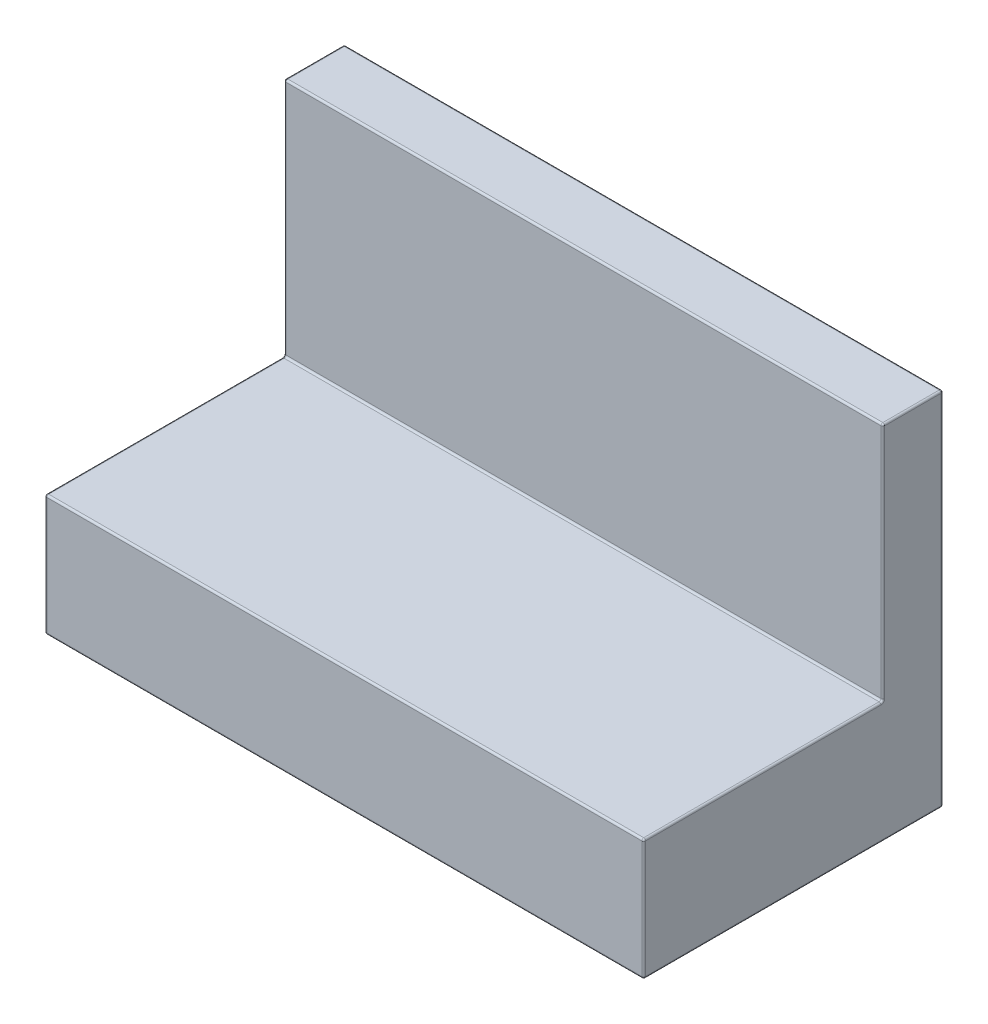
from build123d import *

# Parameters (mm, degrees)
SKETCH1_W       = 7.96
SKETCH1_H       = 7.96
EXTRUDE1_DEPTH  = 3.22
LPATTERN1_COUNT = 2
LPATTERN1_PITCH = 7.96
SHELL1_T        = -1.55
SKETCH4_W       = 12.82
SKETCH4_H       = 4.86
EXTRUDE3_DEPTH  = 0.14
SKETCH5_R       = 1.5
SKETCH5_R_2     = 0.64
EXTRUDE4_DEPTH  = 1.81
SKETCH6_W       = 15.92
SKETCH6_H       = 1.6
EXTRUDE5_DEPTH  = 6.38
FILLET1_R       = 0.05


with BuildPart() as part:
    # Sketch1 → Extrude1 (new body)
    with BuildSketch(Plane(origin=(0, 0, 0), x_dir=(1, 0, 0), z_dir=(0, 1, 0))):
        Rectangle(SKETCH1_W, SKETCH1_H)
    extrude1 = extrude(amount=EXTRUDE1_DEPTH)

    # LPattern1: Extrude1 ×2
    with Locations(*[(i * LPATTERN1_PITCH, 0, 0) for i in range(1, LPATTERN1_COUNT)]):
        add(extrude1)

    # Shell1
    shell1_openings = [part.faces().sort_by_distance(p)[0] for p in [
        (3.98, 0, 0),
    ]]
    offset(amount=SHELL1_T, openings=shell1_openings, kind=Kind.INTERSECTION)

    # Sketch4 → Extrude3 (cut)
    with BuildSketch(Plane.XZ.offset(-1.67)):
        with Locations((3.98, 0)):
            Rectangle(SKETCH4_W, SKETCH4_H)
    extrude(amount=-EXTRUDE3_DEPTH, mode=Mode.SUBTRACT)

    # Sketch5 → Extrude4 (add)
    with BuildSketch(Plane.XZ.offset(-1.81)):
        with Locations((3.98, 0)):
            Circle(SKETCH5_R)
        with Locations((3.98, 0)):
            Circle(SKETCH5_R_2, mode=Mode.SUBTRACT)
    extrude(amount=EXTRUDE4_DEPTH)

    # Sketch6 → Extrude5 (add)
    with BuildSketch(Plane(origin=(0, 3.22, 0), x_dir=(1, 0, 0), z_dir=(0, 1, 0))):
        with Locations((3.98, 3.18)):
            Rectangle(SKETCH6_W, SKETCH6_H)
    extrude(amount=EXTRUDE5_DEPTH)

    # Fillet1
    fillet1_edges = [part.edges().sort_by_distance(p)[0] for p in [
        (3.98, 3.22, 3.98),
        (11.94, 0, 0),
        (11.94, 1.61, 3.98),
        (11.94, 4.8, -3.98),
        (11.94, 3.22, 0.8),
        (3.98, 0, -2.43),
        (10.39, 0.905, -2.43),
        (-2.43, 0, 0),
        (-2.43, 0.905, -2.43),
        (3.98, 0, 2.43),
        (-2.43, 0.905, 2.43),
        (10.39, 0, 0),
        (10.39, 0.905, 2.43),
        (3.98, 1.81, 2.43),
        (10.39, 1.81, 0),
        (3.98, 1.81, -2.43),
        (-2.43, 1.81, 0),
        (3.98, 0, 3.98),
        (2.48, 1.81, 0),
        (-3.98, 0, 0),
        (3.34, 1.81, 0),
        (2.48, 0, 0),
        (3.34, 0, 0),
        (3.98, 0, -3.98),
        (-3.98, 3.22, 0.8),
        (3.98, 3.22, -2.38),
        (-3.98, 6.41, -2.38),
        (11.94, 6.41, -2.38),
        (-3.98, 9.6, -3.18),
        (3.98, 9.6, -2.38),
        (11.94, 9.6, -3.18),
        (3.98, 9.6, -3.98),
        (-3.98, 1.61, 3.98),
        (-3.98, 4.8, -3.98),
    ]]
    fillet(fillet1_edges, radius=FILLET1_R)


solid = part.part
